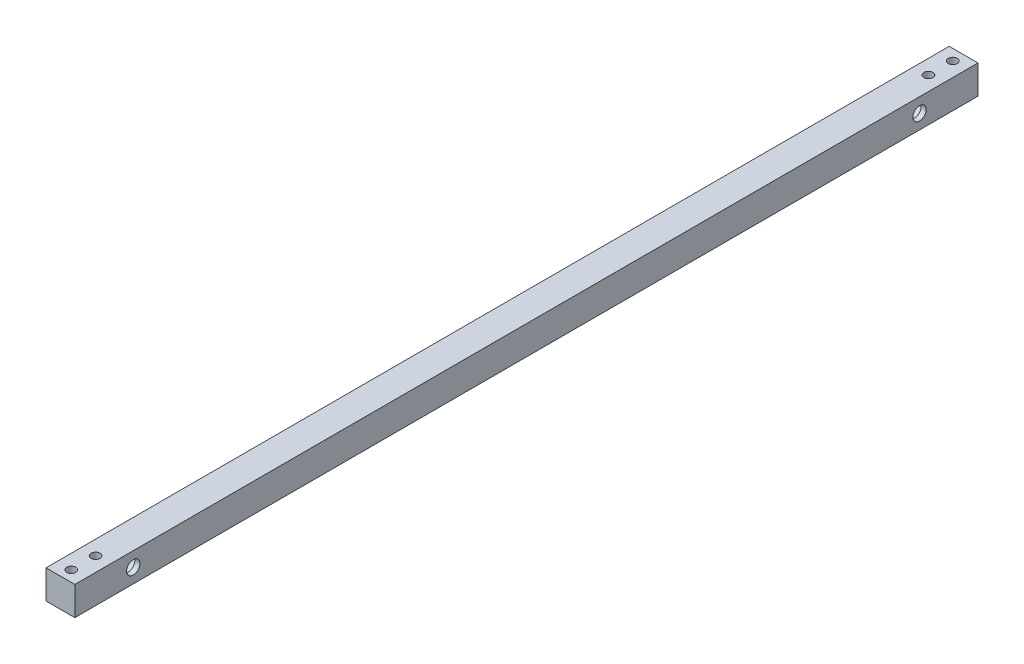
from build123d import *

# Parameters (mm, degrees)
SKETCH1_W                                       = 15.875
SKETCH1_H                                       = 15.875
BOSS_EXTRUDE1_DEPTH                             = 497.84
SKETCH8_R                                       = 6.8199
CUT_EXTRUDE1_DEPTH                              = 13.08608
L_0_29_DIAMETER_HOLE1_D                         = 7.366
L_0_29_DIAMETER_HOLE1_DEPTH                     = 50.8
L_0_29_DIAMETER_HOLE1_TIP                       = 2.21296966
CBORE_FOR_10_SOCKET_HEAD_CAP_SCREW1_D           = 4.9784
CBORE_FOR_10_SOCKET_HEAD_CAP_SCREW1_DEPTH       = 25.4
CBORE_FOR_10_SOCKET_HEAD_CAP_SCREW1_CBORE_D     = 9.525
CBORE_FOR_10_SOCKET_HEAD_CAP_SCREW1_CBORE_DEPTH = 4.826
CBORE_FOR_10_SOCKET_HEAD_CAP_SCREW1_TIP         = 1.495662253
CBORE_FOR_10_SOCKET_HEAD_CAP_SCREW2_D           = 4.9784
CBORE_FOR_10_SOCKET_HEAD_CAP_SCREW2_DEPTH       = 25.4
CBORE_FOR_10_SOCKET_HEAD_CAP_SCREW2_CBORE_D     = 9.525
CBORE_FOR_10_SOCKET_HEAD_CAP_SCREW2_CBORE_DEPTH = 4.826
CBORE_FOR_10_SOCKET_HEAD_CAP_SCREW2_TIP         = 1.495662253


with BuildPart() as part:
    # Sketch1 → Boss-Extrude1 (new body)
    with BuildSketch(Plane.XY):
        with Locations((7.9375, 7.9375)):
            Rectangle(SKETCH1_W, SKETCH1_H)
    extrude(amount=BOSS_EXTRUDE1_DEPTH)

    # Sketch8 → Cut-Extrude1 (cut)
    with BuildSketch(Plane.ZY):
        with Locations((465.6201, 7.9375)):
            Circle(SKETCH8_R)
        with Locations((32.2199, 7.9375)):
            Circle(SKETCH8_R)
    extrude(amount=-CUT_EXTRUDE1_DEPTH, mode=Mode.SUBTRACT)

    # L (0.29) Diameter Hole1
    with Locations(Plane.ZY.offset(-13.08608)):
        with Locations((32.2199, 7.9375), (465.6201, 7.9375)):
            Hole(L_0_29_DIAMETER_HOLE1_D / 2, depth=L_0_29_DIAMETER_HOLE1_DEPTH)
            with Locations((0, 0, -(L_0_29_DIAMETER_HOLE1_DEPTH + L_0_29_DIAMETER_HOLE1_TIP / 2))):  # 118° drill point
                Cone(0, L_0_29_DIAMETER_HOLE1_D / 2, L_0_29_DIAMETER_HOLE1_TIP, mode=Mode.SUBTRACT)

    # CBORE for #10 Socket Head Cap Screw1
    with Locations(Plane(origin=(-863.724136144, 0, -1707.973131805), x_dir=(-1, 0, 0), z_dir=(0, -1, 0))):
        with Locations((-404.936636144, -2199.813131805), (-404.936636144, -2186.413131805), (-871.661636144, -2186.413131805), (-871.661636144, -2199.813131805)):
            CounterBoreHole(CBORE_FOR_10_SOCKET_HEAD_CAP_SCREW1_D / 2, CBORE_FOR_10_SOCKET_HEAD_CAP_SCREW1_CBORE_D / 2, CBORE_FOR_10_SOCKET_HEAD_CAP_SCREW1_CBORE_DEPTH, depth=CBORE_FOR_10_SOCKET_HEAD_CAP_SCREW1_DEPTH)
            with Locations((0, 0, -(CBORE_FOR_10_SOCKET_HEAD_CAP_SCREW1_DEPTH + CBORE_FOR_10_SOCKET_HEAD_CAP_SCREW1_TIP / 2))):  # 118° drill point
                Cone(0, CBORE_FOR_10_SOCKET_HEAD_CAP_SCREW1_D / 2, CBORE_FOR_10_SOCKET_HEAD_CAP_SCREW1_TIP, mode=Mode.SUBTRACT)

    # CBORE for #10 Socket Head Cap Screw2
    with Locations(Plane(origin=(-863.724136144, 0, -1707.973131805), x_dir=(-1, 0, 0), z_dir=(0, -1, 0))):
        with Locations((-404.936636144, -1713.973131805), (-404.936636144, -1727.373131805), (-871.661636144, -1713.973131805), (-871.661636144, -1727.373131805)):
            CounterBoreHole(CBORE_FOR_10_SOCKET_HEAD_CAP_SCREW2_D / 2, CBORE_FOR_10_SOCKET_HEAD_CAP_SCREW2_CBORE_D / 2, CBORE_FOR_10_SOCKET_HEAD_CAP_SCREW2_CBORE_DEPTH, depth=CBORE_FOR_10_SOCKET_HEAD_CAP_SCREW2_DEPTH)
            with Locations((0, 0, -(CBORE_FOR_10_SOCKET_HEAD_CAP_SCREW2_DEPTH + CBORE_FOR_10_SOCKET_HEAD_CAP_SCREW2_TIP / 2))):  # 118° drill point
                Cone(0, CBORE_FOR_10_SOCKET_HEAD_CAP_SCREW2_D / 2, CBORE_FOR_10_SOCKET_HEAD_CAP_SCREW2_TIP, mode=Mode.SUBTRACT)


solid = part.part
